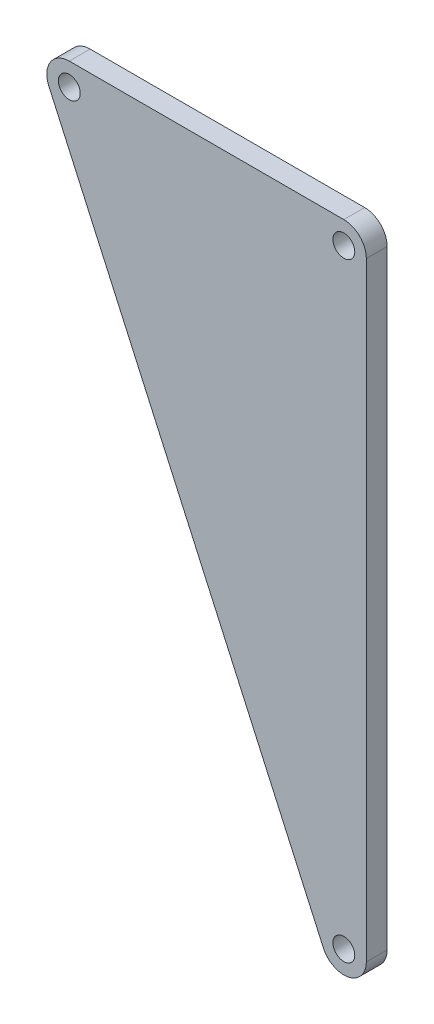
from build123d import *

# Parameters (mm, degrees)
SKETCH1_R           = 4.32
SKETCH1_R_2         = 2.1
BOSS_EXTRUDE1_DEPTH = 4


with BuildPart() as part:
    # Sketch1 → Boss-Extrude1 (new body)
    with BuildSketch(Plane.XY):
        with BuildLine():
            Line((52.7, 4.32), (0, 4.32))
            ThreePointArc((0, 4.32), (3.054701295, 3.054701295), (4.32, 0))
            ThreePointArc((4.32, 0), (0.907798653, -4.223541358), (-3.938472965, -1.775057943))
            Line((-3.938472965, -1.775057943), (48.761527035, -118.705057943))
            ThreePointArc((48.761527035, -118.705057943), (51.792201347, -112.706458642), (57.02, -116.93))
            Line((57.02, -116.93), (57.02, 0))
            ThreePointArc((57.02, 0), (49.645298705, -3.054701295), (52.7, 4.32))
        make_face()
        Circle(SKETCH1_R)
        Circle(SKETCH1_R_2, mode=Mode.SUBTRACT)
        with Locations((52.7, 0)):
            Circle(SKETCH1_R)
        with Locations((52.7, 0)):
            Circle(SKETCH1_R_2, mode=Mode.SUBTRACT)
        with Locations((52.7, -116.93)):
            Circle(SKETCH1_R)
        with Locations((52.7, -116.93)):
            Circle(SKETCH1_R_2, mode=Mode.SUBTRACT)
    extrude(amount=BOSS_EXTRUDE1_DEPTH)


solid = part.part
